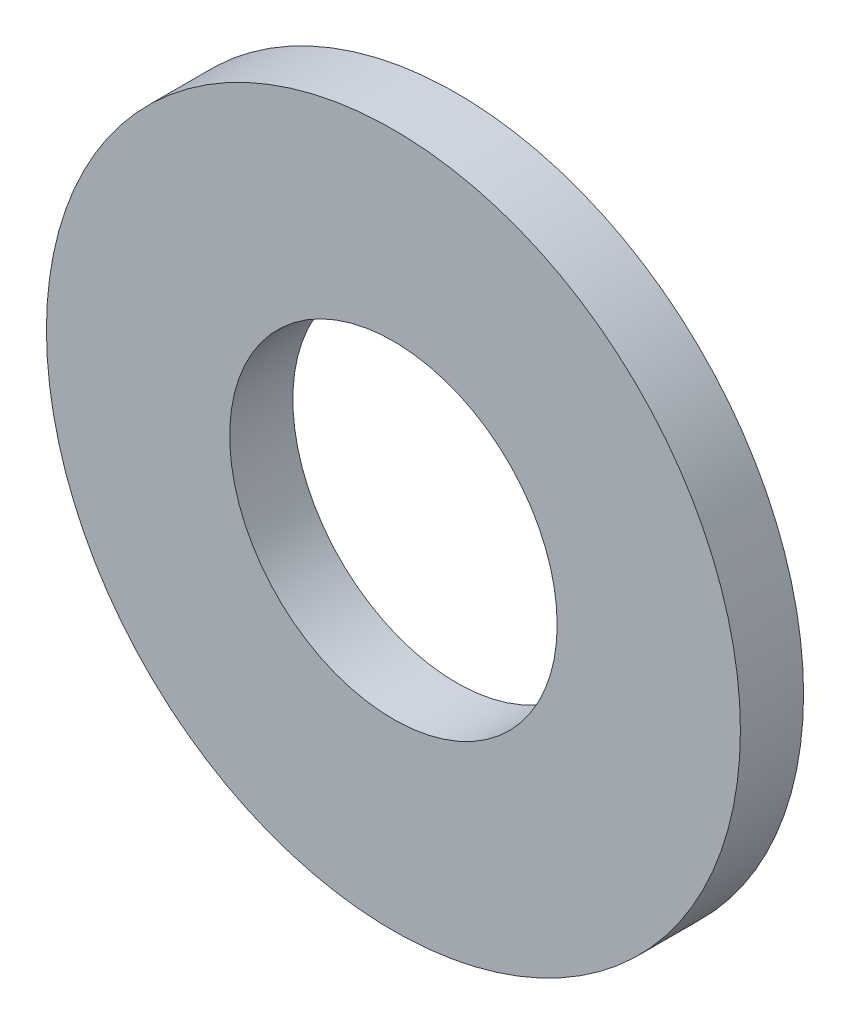
from build123d import *

# Parameters (mm, degrees)
SKETCH1_R           = 4.45
SKETCH1_R_2         = 2.1
BOSS_EXTRUDE1_DEPTH = 0.81


with BuildPart() as part:
    # Sketch1 → Boss-Extrude1 (new body)
    with BuildSketch(Plane.XY):
        Circle(SKETCH1_R)
        Circle(SKETCH1_R_2, mode=Mode.SUBTRACT)
    extrude(amount=BOSS_EXTRUDE1_DEPTH)


solid = part.part
